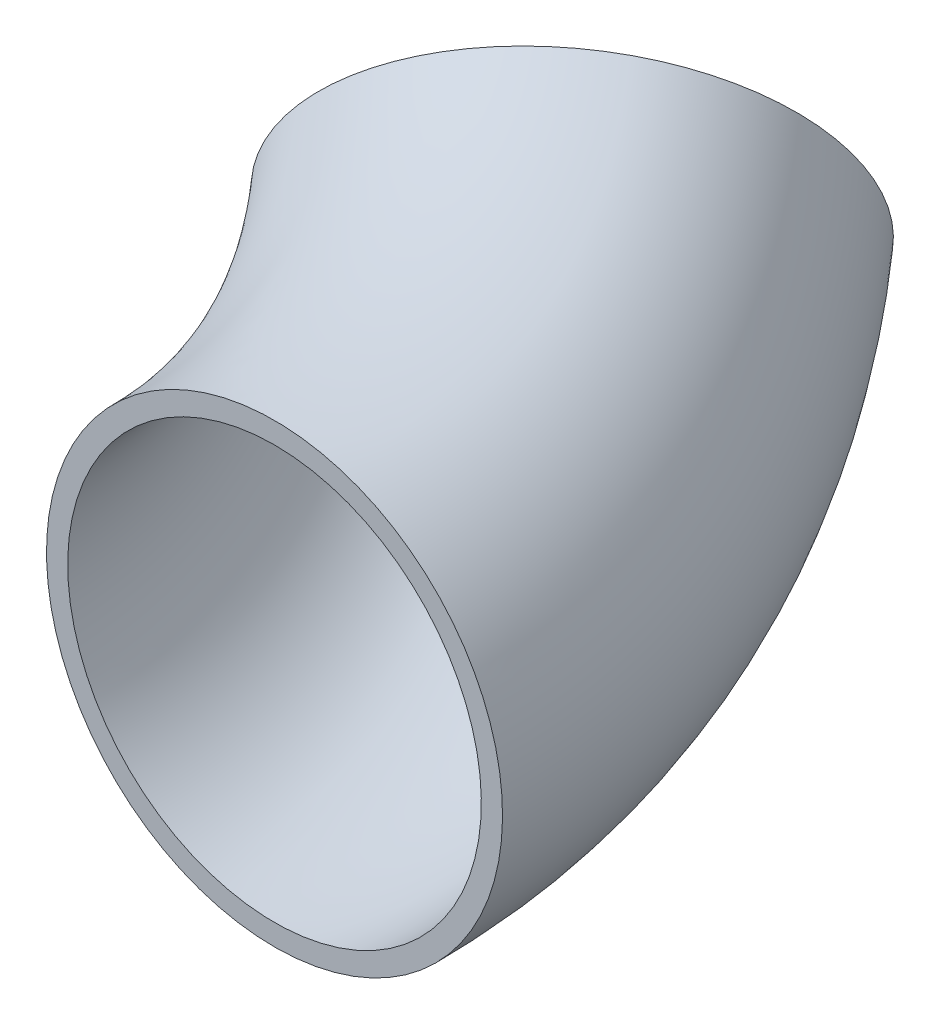
from build123d import *

# Parameters (mm, degrees)
PIPESKETCH_R   = 136.525
PIPESKETCH_R_2 = 123.825


with BuildPart() as part:
    # Sweep-Thin1: sweep along a curve in space
    with BuildLine() as sweep_thin1_path:
        ThreePointArc((0, 0, 0), (-23.67995065, 16.744253683, -145.802387731), (-91.114744772, 64.427853895, -269.407683632))
    # PipeSketch → Sweep-Thin1 (sweep)
    with BuildSketch(Plane.XY):
        Circle(PIPESKETCH_R)
        Circle(PIPESKETCH_R_2, mode=Mode.SUBTRACT)
    sweep(path=sweep_thin1_path.line)


solid = part.part
